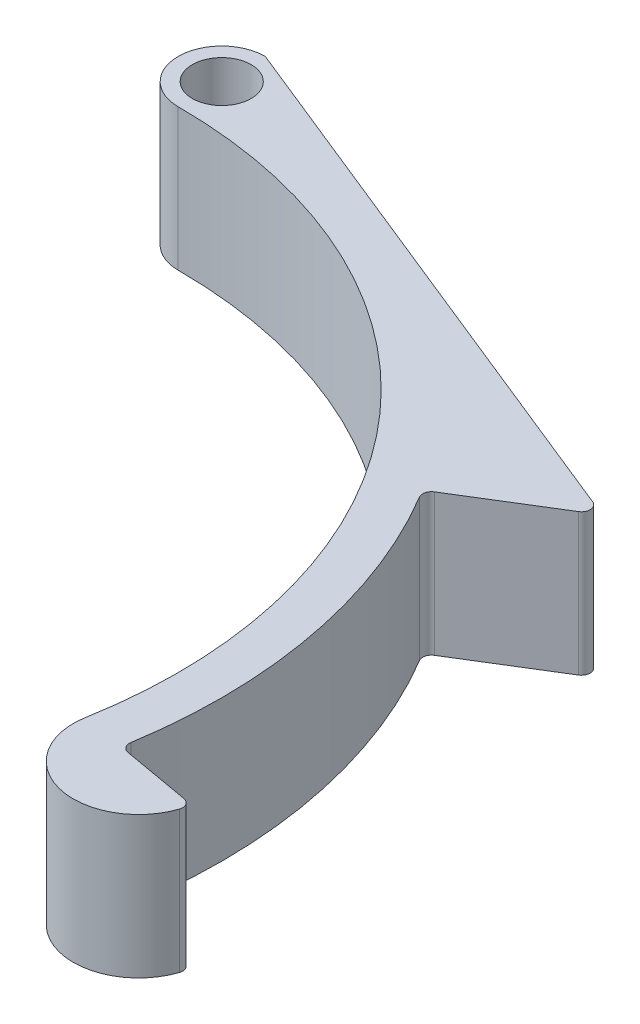
from build123d import *

# Parameters (mm, degrees)
BOSS_EXTRUDE1_DEPTH = 13
FILLET1_R           = 0.8


with BuildPart() as part:
    # Sketch1 → Boss-Extrude1 (new body)
    with BuildSketch(Plane(origin=(0, 0, 0), x_dir=(1, 0, 0), z_dir=(0, 1, 0))):
        with BuildLine():
            Line((0, 51.7), (0, 53))
            ThreePointArc((0, 53), (-4, 49), (0, 45))
            ThreePointArc((0, 45), (34.47199994, 28.925442436), (44.316348886, -7.814167995))
            ThreePointArc((44.316348886, -7.814167995), (49.183306338, -14.764903579), (56.134041922, -9.897946127))
            Line((56.134041922, -9.897946127), (48.255579898, -8.508760706))
            ThreePointArc((48.255579898, -8.508760706), (48.127142564, 9.207505018), (41.707047143, 25.720074234))
            ThreePointArc((41.707047143, 25.720074234), (25.051905135, 42.111780407), (2.698975076, 48.925612245))
            ThreePointArc((2.698975076, 48.925612245), (-1.935309657, 47.117295421), (0, 51.7))
        make_face()
        with BuildLine():
            Line((51.921017872, 32.018867925), (0, 53))
            Line((0, 53), (0, 51.7))
            ThreePointArc((0, 51.7), (1.909188309, 50.909188309), (2.7, 49))
            ThreePointArc((2.7, 49), (2.699743757, 48.962802592), (2.698975076, 48.925612245))
            ThreePointArc((2.698975076, 48.925612245), (25.051905135, 42.111780407), (41.707047143, 25.720074234))
            Line((41.707047143, 25.720074234), (51.921017872, 32.018867925))
        make_face()
    extrude(amount=BOSS_EXTRUDE1_DEPTH)

    # Fillet1
    fillet1_edges = [part.edges().sort_by_distance(p)[0] for p in [
        (0, 6.5, -53),
        (51.921017872, 6.5, -32.018867925),
        (41.707047143, 6.5, -25.720074234),
        (48.255579898, 6.5, 8.508760706),
        (56.134041922, 6.5, 9.897946127),
    ]]
    fillet(fillet1_edges, radius=FILLET1_R)


solid = part.part
